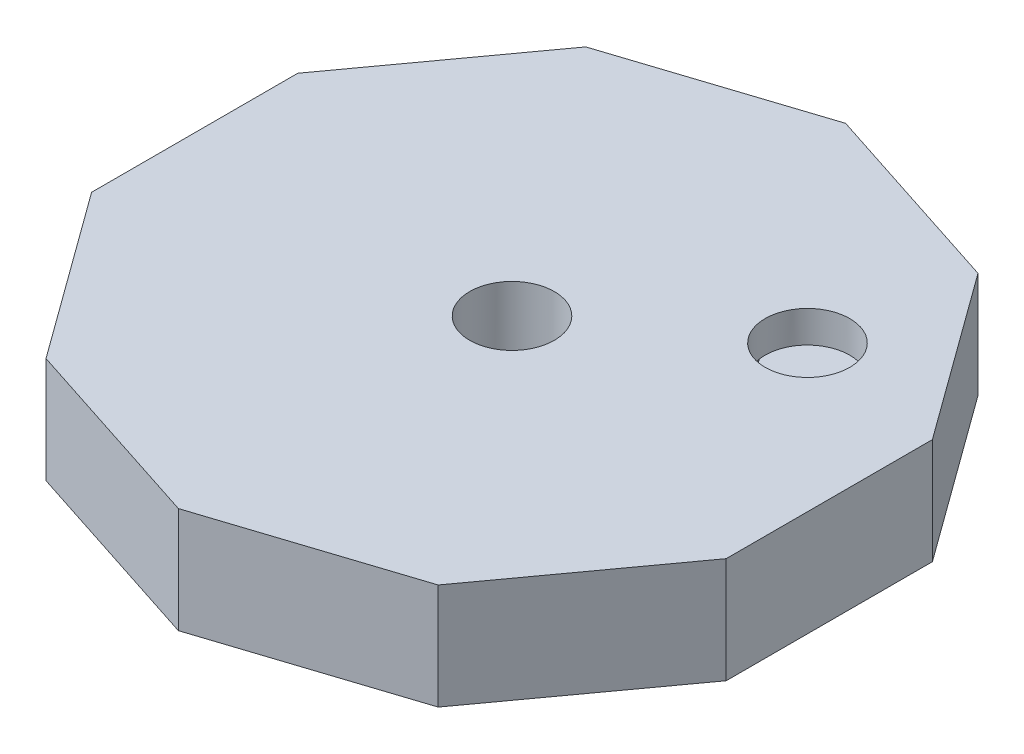
from build123d import *

# Parameters (mm, degrees)
BOSS_EXTRUDE1_DEPTH     = 5
SKETCH2_R               = 2
CUT_EXTRUDE1_DEPTH      = 5
SKETCH4_R               = 3
CUT_EXTRUDE2_DEPTH      = 1.5
SKETCH25_R              = 2
CUT_EXTRUDE3_DEPTH      = 2
SKETCH19_R              = 2
CUT_EXTRUDE4_DEPTH      = 3
SKETCH26_W              = 14.53085056
SKETCH26_H              = 1
CUT_EXTRUDE5_DEPTH      = 2
CUT_EXTRUDE5_DEPTH_BACK = 2


with BuildPart() as part:
    # Sketch1 → Boss-Extrude1 (new body)
    with BuildSketch(Plane(origin=(0, 0, 0), x_dir=(1, 0, 0), z_dir=(0, 1, 0))):
        Polygon((9.270509831, -12.759762125), (15, -4.873795443), (15, 4.873795443), (9.270509831, 12.759762125), (0, 15.771933364), (-9.270509831, 12.759762125), (-15, 4.873795443), (-15, -4.873795443), (-9.270509831, -12.759762125), (0, -15.771933364), align=None)
    extrude(amount=BOSS_EXTRUDE1_DEPTH)

    # Sketch2 → Cut-Extrude1 (cut)
    with BuildSketch(Plane(origin=(0, 5, 0), x_dir=(1, 0, 0), z_dir=(0, 1, 0))):
        Circle(SKETCH2_R)
    extrude(amount=-CUT_EXTRUDE1_DEPTH, mode=Mode.SUBTRACT)

    # Sketch4 → Cut-Extrude2 (cut)
    with BuildSketch(Plane.XZ):
        Circle(SKETCH4_R)
    extrude(amount=-CUT_EXTRUDE2_DEPTH, mode=Mode.SUBTRACT)

    # Sketch25 → Cut-Extrude3 (cut)
    with BuildSketch(Plane(origin=(0, 5, 0), x_dir=(1, 0, 0), z_dir=(0, 1, 0))):
        with Locations((8.090169944, 5.877852523)):
            Circle(SKETCH25_R)
    extrude(amount=-CUT_EXTRUDE3_DEPTH, mode=Mode.SUBTRACT)

    # Sketch19 → Cut-Extrude4 (cut)
    with BuildSketch(Plane.XZ):
        with Locations((12.360679775, 0)):
            Circle(SKETCH19_R)
        with Locations((3.819660113, -11.755705046)):
            Circle(SKETCH19_R)
    extrude(amount=-CUT_EXTRUDE4_DEPTH, mode=Mode.SUBTRACT)

    # Sketch26 → Cut-Extrude5 (cut, two sides)
    with BuildSketch(Plane(origin=(8.090169944, 0, -5.877852523), x_dir=(-0.587785252, 0, -0.809016994), z_dir=(-0.809016994, 0, 0.587785252))) as cut_extrude5_sk:
        with Locations((0, -3)):
            Rectangle(SKETCH26_W, SKETCH26_H)
    extrude(amount=CUT_EXTRUDE5_DEPTH, mode=Mode.SUBTRACT)
    extrude(cut_extrude5_sk.sketch, amount=-CUT_EXTRUDE5_DEPTH_BACK, mode=Mode.SUBTRACT)


solid = part.part
